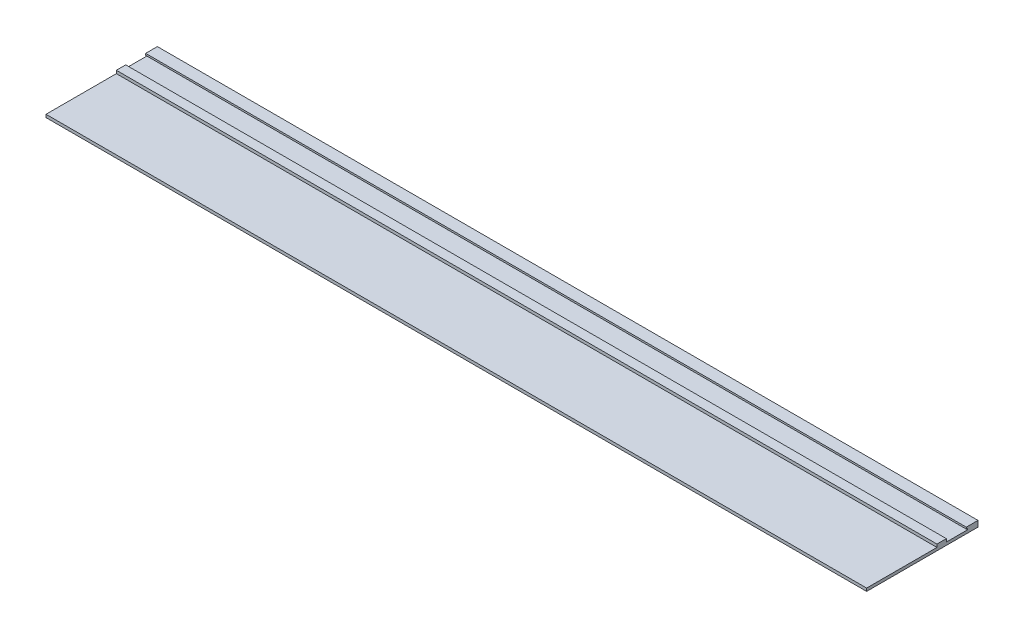
from build123d import *

# Parameters (mm, degrees)
EXTRUDE_1_DEPTH = 1400


with BuildPart() as part:
    # Эскиз1 → Бобышка-Вытянуть1 (new body)
    with BuildSketch(Plane(origin=(0, 0, 0), x_dir=(0, 0, -1), z_dir=(1, 0, 0))):
        Polygon((0, 0), (190, 0), (190, 10), (170, 10), (170, 7.123809524), (172.06333875, 7.123809524), (172.06333875, 4.986666667), (136, 4.986666667), (136, 10), (120, 10), (120, 4.986666667), (0, 4.986666667), align=None)
    extrude(amount=EXTRUDE_1_DEPTH)


solid = part.part
